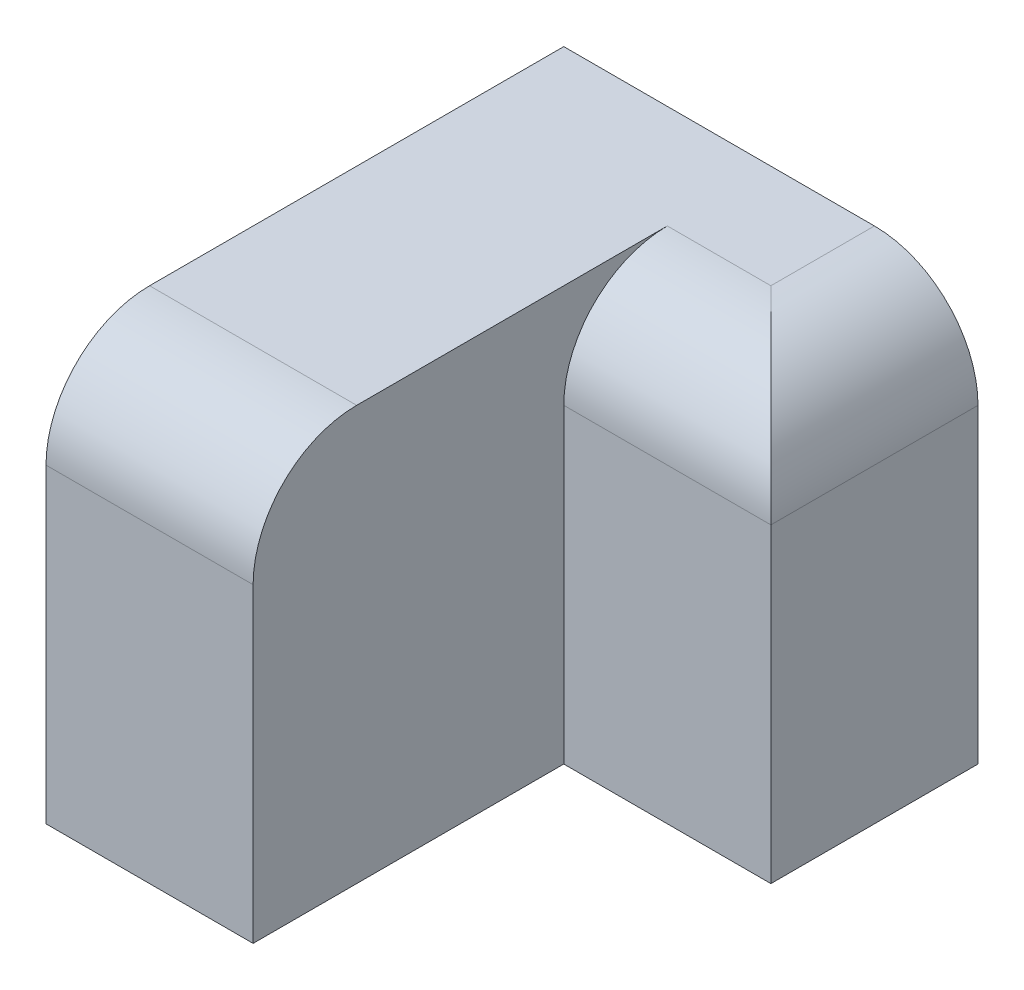
from build123d import *

# Parameters (mm, degrees)
SKETCH1_W           = 20
SKETCH1_H           = 40
BOSS_EXTRUDE1_DEPTH = 30
SKETCH2_W           = 40
SKETCH2_H           = 40
BOSS_EXTRUDE2_DEPTH = 20
FILLET1_R           = 10


with BuildPart() as part:
    # Sketch1 → Boss-Extrude1 (new body)
    with BuildSketch(Plane.XY):
        with Locations((-20, -20)):
            Rectangle(SKETCH1_W, SKETCH1_H)
    extrude(amount=BOSS_EXTRUDE1_DEPTH)

    # Sketch2 → Boss-Extrude2 (add)
    with BuildSketch(Plane.XY):
        with Locations((-10, -20)):
            Rectangle(SKETCH2_W, SKETCH2_H)
    extrude(amount=-BOSS_EXTRUDE2_DEPTH)

    # Fillet1
    fillet1_edges = [part.edges().sort_by_distance(p)[0] for p in [
        (0, 0, 0),
        (10, 0, -10),
        (-20, 0, 30),
    ]]
    fillet(fillet1_edges, radius=FILLET1_R)


solid = part.part
